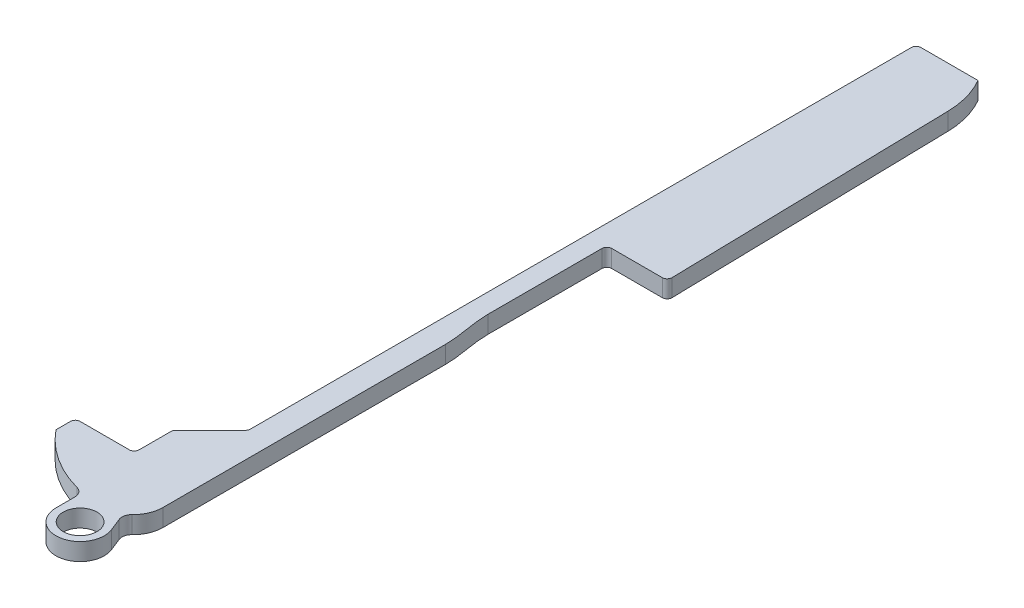
from build123d import *

# Parameters (mm, degrees)
BOSS_EXTRUDE1_DEPTH = 1.8
FILLET2_R           = 0.5
SKETCH3_R           = 2.5
SKETCH3_R_2         = 1.75
BOSS_EXTRUDE2_DEPTH = 1.8
FILLET3_R           = 1


with BuildPart() as part:
    # Sketch1 → Boss-Extrude1 (new body)
    with BuildSketch(Plane(origin=(0, 0, 0), x_dir=(1, 0, 0), z_dir=(0, 1, 0))):
        with BuildLine():
            Line((0, 4.5), (0, 6.5))
            Line((0, 6.5), (6.1, 6.5))
            Line((6.1, 6.5), (6.1, 10.5))
            Line((6.1, 10.5), (10, 14.4))
            Line((10, 14.4), (10, 83.5))
            Line((10, 83.5), (16.4, 83.5))
            ThreePointArc((16.4, 83.5), (17.2719581, 81.425344658), (17.601960582, 79.199226044))
            Line((17.601960582, 79.199226044), (18.25, 49.5))
            Line((18.25, 49.5), (12, 49.5))
            Line((12, 49.5), (12, 37.18))
            add(Edge.make_bspline(
                [(12.5, 32.33), (12.5, 33.972282338), (12, 35.554764974), (12, 37.18)],
                knots=[0, 0, 0, 0, 1, 1, 1, 1], degree=3))
            Line((12.5, 32.33), (12.5, 3.07))
            ThreePointArc((12.5, 3.07), (11.600817818, 0.899182182), (9.43, 0))
            ThreePointArc((9.43, 0), (4.205660329, 1.182650422), (0, 4.5))
        make_face()
    extrude(amount=BOSS_EXTRUDE1_DEPTH)

    # Fillet2
    fillet2_edges = [part.edges().sort_by_distance(p)[0] for p in [
        (0, 0.9, -6.5),
        (6.1, 0.9, -6.5),
        (6.1, 0.9, -10.5),
        (10, 0.9, -14.4),
        (10, 0.9, -83.5),
        (18.25, 0.9, -49.5),
        (12, 0.9, -49.5),
    ]]
    fillet(fillet2_edges, radius=FILLET2_R)

    # Sketch3 → Boss-Extrude2 (add)
    with BuildSketch(Plane.XZ):
        with Locations((9.5, 2.499832541)):
            Circle(SKETCH3_R)
        with Locations((9.5, 2.499832541)):
            Circle(SKETCH3_R_2, mode=Mode.SUBTRACT)
        with BuildLine():
            ThreePointArc((11.824045318, 1.578521867), (9.031018815, 0.044215175), (7, 2.499832541))
            Line((7, 2.499832541), (7, -0.245881701))
            ThreePointArc((7, -0.245881701), (8.2087959, -0.061626967), (9.43, 0))
            ThreePointArc((9.43, 0), (10.256451345, -0.113333266), (11.021883517, -0.444965358))
            Line((11.021883517, -0.444965358), (11.824045318, 1.578521867))
        make_face()
        with BuildLine():
            ThreePointArc((9.43, 0), (8.2087959, -0.061626967), (7, -0.245881701))
            Line((7, -0.245881701), (7, -0.500167459))
            Line((7, -0.500167459), (11, -0.500167459))
            Line((11, -0.500167459), (11.021883517, -0.444965358))
            ThreePointArc((11.021883517, -0.444965358), (10.256451345, -0.113333266), (9.43, 0))
        make_face()
    extrude(amount=-BOSS_EXTRUDE2_DEPTH)

    # Fillet3
    fillet3_edges = [part.edges().sort_by_distance(p)[0] for p in [
        (7, 0.9, -0.245881701),
        (11.021883517, 0.9, -0.444965358),
    ]]
    fillet(fillet3_edges, radius=FILLET3_R)


solid = part.part
